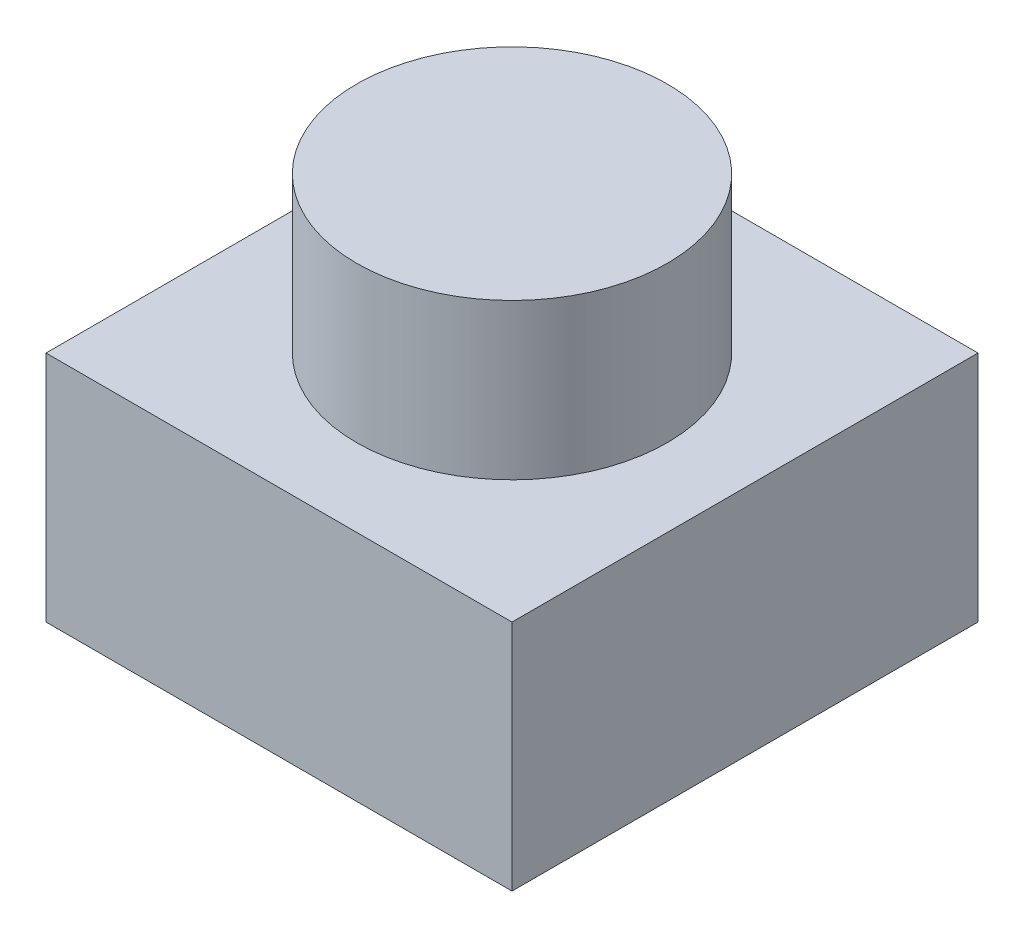
from build123d import *

# Parameters (mm, degrees)
SKETCH1_W           = 6
SKETCH1_H           = 6
BOSS_EXTRUDE1_DEPTH = 3
SKETCH2_R           = 2
BOSS_EXTRUDE2_DEPTH = 2


with BuildPart() as part:
    # Sketch1 → Boss-Extrude1 (new body)
    with BuildSketch(Plane(origin=(0, 0, 0), x_dir=(1, 0, 0), z_dir=(0, 1, 0))):
        Rectangle(SKETCH1_W, SKETCH1_H)
    extrude(amount=BOSS_EXTRUDE1_DEPTH)

    # Sketch2 → Boss-Extrude2 (add)
    with BuildSketch(Plane(origin=(0, 3, 0), x_dir=(1, 0, 0), z_dir=(0, 1, 0))):
        Circle(SKETCH2_R)
    extrude(amount=BOSS_EXTRUDE2_DEPTH)


solid = part.part
